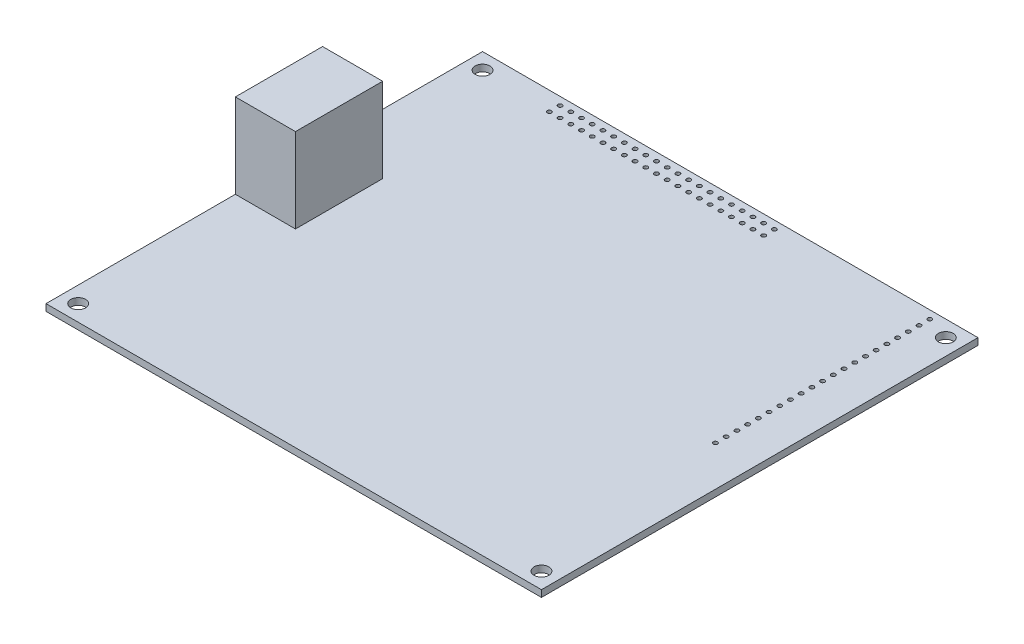
from build123d import *

# Parameters (mm, degrees)
SKETCH1_W           = 117.475
SKETCH1_H           = 103.505
SKETCH1_R           = 1.7526
BOSS_EXTRUDE1_DEPTH = 1.6
SKETCH2_W           = 14.25
SKETCH2_H           = 20.676
BOSS_EXTRUDE2_DEPTH = 20
SKETCH3_R           = 0.5
CUT_EXTRUDE1_DEPTH  = 2.6


with BuildPart() as part:
    # Sketch1 → Boss-Extrude1 (new body)
    with BuildSketch(Plane(origin=(0, 0, 0), x_dir=(1, 0, 0), z_dir=(0, 1, 0))):
        with Locations((58.7375, 51.7525)):
            Rectangle(SKETCH1_W, SKETCH1_H)
        with Locations((3.815, 3.815)):
            Circle(SKETCH1_R, mode=Mode.SUBTRACT)
        with Locations((113.66, 3.815)):
            Circle(SKETCH1_R, mode=Mode.SUBTRACT)
        with Locations((113.66, 99.69)):
            Circle(SKETCH1_R, mode=Mode.SUBTRACT)
        with Locations((3.815, 99.69)):
            Circle(SKETCH1_R, mode=Mode.SUBTRACT)
    extrude(amount=BOSS_EXTRUDE1_DEPTH)

    # Sketch2 → Boss-Extrude2 (add)
    with BuildSketch(Plane(origin=(0, 1.6, 0), x_dir=(1, 0, 0), z_dir=(0, 1, 0))):
        with Locations((7.125, 55.239)):
            Rectangle(SKETCH2_W, SKETCH2_H)
    extrude(amount=BOSS_EXTRUDE2_DEPTH)

    # Sketch3 → Cut-Extrude1 (cut, through all)
    with BuildSketch(Plane(origin=(0, 1.6, 0), x_dir=(1, 0, 0), z_dir=(0, 1, 0))):
        with Locations((20.285, 101.605)):
            Circle(SKETCH3_R)
        with Locations((22.825, 101.605)):
            Circle(SKETCH3_R)
        with Locations((25.365, 101.605)):
            Circle(SKETCH3_R)
        with Locations((27.905, 101.605)):
            Circle(SKETCH3_R)
        with Locations((30.445, 101.605)):
            Circle(SKETCH3_R)
        with Locations((32.985, 101.605)):
            Circle(SKETCH3_R)
        with Locations((35.525, 101.605)):
            Circle(SKETCH3_R)
        with Locations((38.065, 101.605)):
            Circle(SKETCH3_R)
        with Locations((40.605, 101.605)):
            Circle(SKETCH3_R)
        with Locations((43.145, 101.605)):
            Circle(SKETCH3_R)
        with Locations((45.685, 101.605)):
            Circle(SKETCH3_R)
        with Locations((48.225, 101.605)):
            Circle(SKETCH3_R)
        with Locations((50.765, 101.605)):
            Circle(SKETCH3_R)
        with Locations((53.305, 101.605)):
            Circle(SKETCH3_R)
        with Locations((55.845, 101.605)):
            Circle(SKETCH3_R)
        with Locations((58.385, 101.605)):
            Circle(SKETCH3_R)
        with Locations((60.925, 101.605)):
            Circle(SKETCH3_R)
        with Locations((63.465, 101.605)):
            Circle(SKETCH3_R)
        with Locations((66.005, 101.605)):
            Circle(SKETCH3_R)
        with Locations((68.545, 101.605)):
            Circle(SKETCH3_R)
        with Locations((71.085, 101.605)):
            Circle(SKETCH3_R)
        with Locations((22.825, 99.065)):
            Circle(SKETCH3_R)
        with Locations((25.365, 99.065)):
            Circle(SKETCH3_R)
        with Locations((27.905, 99.065)):
            Circle(SKETCH3_R)
        with Locations((30.445, 99.065)):
            Circle(SKETCH3_R)
        with Locations((32.985, 99.065)):
            Circle(SKETCH3_R)
        with Locations((35.525, 99.065)):
            Circle(SKETCH3_R)
        with Locations((38.065, 99.065)):
            Circle(SKETCH3_R)
        with Locations((40.605, 99.065)):
            Circle(SKETCH3_R)
        with Locations((43.145, 99.065)):
            Circle(SKETCH3_R)
        with Locations((45.685, 99.065)):
            Circle(SKETCH3_R)
        with Locations((48.225, 99.065)):
            Circle(SKETCH3_R)
        with Locations((50.765, 99.065)):
            Circle(SKETCH3_R)
        with Locations((53.305, 99.065)):
            Circle(SKETCH3_R)
        with Locations((55.845, 99.065)):
            Circle(SKETCH3_R)
        with Locations((58.385, 99.065)):
            Circle(SKETCH3_R)
        with Locations((60.925, 99.065)):
            Circle(SKETCH3_R)
        with Locations((63.465, 99.065)):
            Circle(SKETCH3_R)
        with Locations((66.005, 99.065)):
            Circle(SKETCH3_R)
        with Locations((68.545, 99.065)):
            Circle(SKETCH3_R)
        with Locations((71.085, 99.065)):
            Circle(SKETCH3_R)
        with Locations((20.285, 99.065)):
            Circle(SKETCH3_R)
        with Locations((107.97, 101.565)):
            Circle(SKETCH3_R)
        with Locations((107.97, 99.025)):
            Circle(SKETCH3_R)
        with Locations((107.97, 96.485)):
            Circle(SKETCH3_R)
        with Locations((107.97, 93.945)):
            Circle(SKETCH3_R)
        with Locations((107.97, 91.405)):
            Circle(SKETCH3_R)
        with Locations((107.97, 88.865)):
            Circle(SKETCH3_R)
        with Locations((107.97, 86.325)):
            Circle(SKETCH3_R)
        with Locations((107.97, 83.785)):
            Circle(SKETCH3_R)
        with Locations((107.97, 81.245)):
            Circle(SKETCH3_R)
        with Locations((107.97, 78.705)):
            Circle(SKETCH3_R)
        with Locations((107.97, 76.165)):
            Circle(SKETCH3_R)
        with Locations((107.97, 73.625)):
            Circle(SKETCH3_R)
        with Locations((107.97, 71.085)):
            Circle(SKETCH3_R)
        with Locations((107.97, 68.545)):
            Circle(SKETCH3_R)
        with Locations((107.97, 66.005)):
            Circle(SKETCH3_R)
        with Locations((107.97, 63.465)):
            Circle(SKETCH3_R)
        with Locations((107.97, 60.925)):
            Circle(SKETCH3_R)
        with Locations((107.97, 58.385)):
            Circle(SKETCH3_R)
        with Locations((107.97, 55.845)):
            Circle(SKETCH3_R)
        with Locations((107.97, 53.305)):
            Circle(SKETCH3_R)
        with Locations((107.97, 50.765)):
            Circle(SKETCH3_R)
    extrude(amount=-CUT_EXTRUDE1_DEPTH, mode=Mode.SUBTRACT)


solid = part.part
